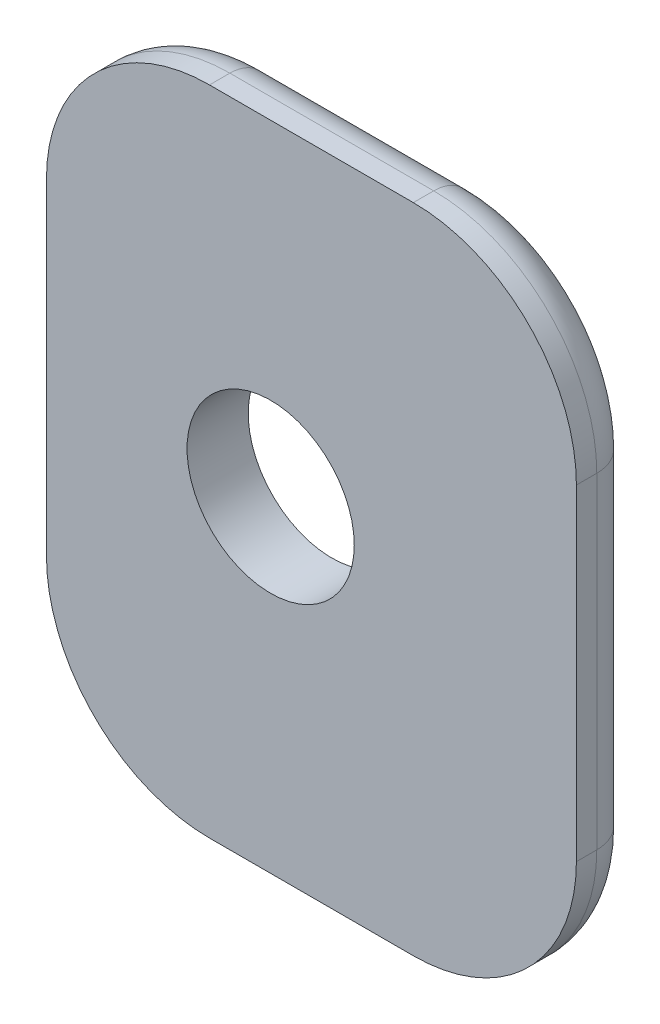
from build123d import *

# Parameters (mm, degrees)
SKETCH1_W           = 26
SKETCH1_H           = 32
SKETCH1_R           = 4.1021
BOSS_EXTRUDE1_DEPTH = 3
FILLET1_R           = 8
FILLET2_R           = 2


with BuildPart() as part:
    # Sketch1 → Boss-Extrude1 (new body)
    with BuildSketch(Plane.XY):
        with Locations((2, 0)):
            Rectangle(SKETCH1_W, SKETCH1_H)
        Circle(SKETCH1_R, mode=Mode.SUBTRACT)
    extrude(amount=BOSS_EXTRUDE1_DEPTH)

    # Fillet1
    fillet1_edges = [part.edges().sort_by_distance(p)[0] for p in [
        (15, -16, 1.5),
        (-11, -16, 1.5),
        (-11, 16, 1.5),
        (15, 16, 1.5),
    ]]
    fillet(fillet1_edges, radius=FILLET1_R)

    # Fillet2
    fillet2_edges = [part.edges().sort_by_distance(p)[0] for p in [
        (15, 0, 0),
        (2, -16, 0),
        (-11, 0, 0),
        (2, 16, 0),
        (-8.656854249, 13.656854249, 0),
        (12.656854249, 13.656854249, 0),
        (-8.656854249, -13.656854249, 0),
        (12.656854249, -13.656854249, 0),
    ]]
    fillet(fillet2_edges, radius=FILLET2_R)


solid = part.part
